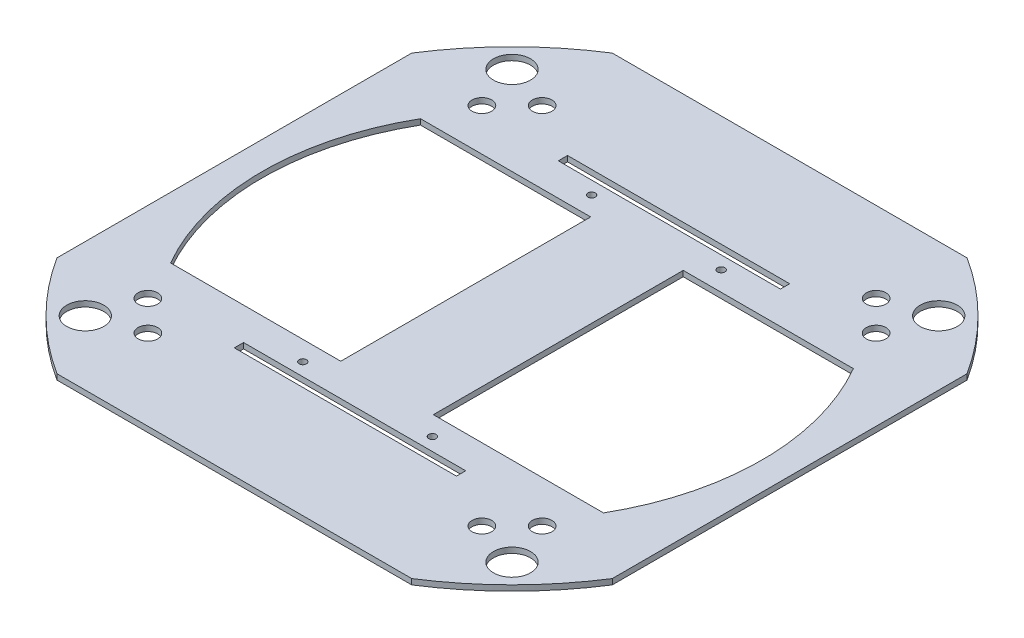
from build123d import *

# Parameters (mm, degrees)
SKETCH_3_R          = 178
EXTRUDE_3_DEPTH     = 3
SKETCH_4_R          = 10
SKETCH_4_R_2        = 5.3
CUT_EXTRUDE_1_DEPTH = 10
CUT_EXTRUDE_2_DEPTH = 10
SKETCH_6_R          = 2
SKETCH_6_W          = 120
SKETCH_6_H          = 5
CUT_EXTRUDE_3_DEPTH = 10


with BuildPart() as part:
    # 草图3 → 凸台-拉伸3 (new body)
    with BuildSketch(Plane(origin=(0, 0, 0), x_dir=(1, 0, 0), z_dir=(0, 1, 0))):
        Circle(SKETCH_3_R)
        with BuildLine():
            Line((-25, 33.75), (-25, -67.5))
            Line((-25, -67.5), (-116.913429511, -67.5))
            ThreePointArc((-116.913429511, -67.5), (-135, 0), (-116.913429511, 67.5))
            Line((-116.913429511, 67.5), (-25, 67.5))
            Line((-25, 67.5), (-25, 33.75))
        make_face(mode=Mode.SUBTRACT)
        with BuildLine():
            Line((25, 33.75), (25, 67.5))
            Line((25, 67.5), (116.913429511, 67.5))
            ThreePointArc((116.913429511, 67.5), (135, 0), (116.913429511, -67.5))
            Line((116.913429511, -67.5), (25, -67.5))
            Line((25, -67.5), (25, 33.75))
        make_face(mode=Mode.SUBTRACT)
    extrude(amount=EXTRUDE_3_DEPTH)

    # 草图4 → 切除-拉伸1 (cut)
    with BuildSketch(Plane(origin=(0, 3, 0), x_dir=(1, 0, 0), z_dir=(0, 1, 0))):
        with Locations((115.258405333, 115.258405333)):
            Circle(SKETCH_4_R)
        with Locations((115.258405333, -115.258405333)):
            Circle(SKETCH_4_R)
        with Locations((-115.258405333, -115.258405333)):
            Circle(SKETCH_4_R)
        with Locations((-115.258405333, 115.258405333)):
            Circle(SKETCH_4_R)
        with Locations((-90.216925784, -106.480381752)):
            Circle(SKETCH_4_R_2)
        with Locations((-106.480381752, -90.216925784)):
            Circle(SKETCH_4_R_2)
        with Locations((-106.480381752, 90.216925784)):
            Circle(SKETCH_4_R_2)
        with Locations((-90.216925784, 106.480381752)):
            Circle(SKETCH_4_R_2)
        with Locations((90.216925784, 106.480381752)):
            Circle(SKETCH_4_R_2)
        with Locations((106.480381752, 90.216925784)):
            Circle(SKETCH_4_R_2)
        with Locations((106.480381752, -90.216925784)):
            Circle(SKETCH_4_R_2)
        with Locations((90.216925784, -106.480381752)):
            Circle(SKETCH_4_R_2)
    extrude(amount=-CUT_EXTRUDE_1_DEPTH, mode=Mode.SUBTRACT)

    # 草图5 → 切除-拉伸2 (cut)
    with BuildSketch(Plane(origin=(0, 3, 0), x_dir=(1, 0, 0), z_dir=(0, 1, 0))):
        with BuildLine():
            Line((95.833188406, 150), (0, 150))
            Line((0, 150), (-95.833188406, 150))
            ThreePointArc((-95.833188406, 150), (0, 178), (95.833188406, 150))
        make_face()
        with BuildLine():
            Line((150, 95.833188406), (150, 0))
            Line((150, 0), (150, -95.833188406))
            ThreePointArc((150, -95.833188406), (178, 0), (150, 95.833188406))
        make_face()
        with BuildLine():
            Line((95.833188406, -150), (0, -150))
            Line((0, -150), (-95.833188406, -150))
            ThreePointArc((-95.833188406, -150), (0, -178), (95.833188406, -150))
        make_face()
        with BuildLine():
            Line((-150, 0), (-150, -95.833188406))
            ThreePointArc((-150, -95.833188406), (-178, 0), (-150, 95.833188406))
            Line((-150, 95.833188406), (-150, 0))
        make_face()
    extrude(amount=-CUT_EXTRUDE_2_DEPTH, mode=Mode.SUBTRACT)

    # 草图6 → 切除-拉伸3 (cut)
    with BuildSketch(Plane(origin=(0, 3, 0), x_dir=(1, 0, 0), z_dir=(0, 1, 0))):
        with Locations((35, -78)):
            Circle(SKETCH_6_R)
        with Locations((-35, -78)):
            Circle(SKETCH_6_R)
        with Locations((-35, 78)):
            Circle(SKETCH_6_R)
        with Locations((35, 78)):
            Circle(SKETCH_6_R)
        with Locations((0, -87.5)):
            Rectangle(SKETCH_6_W, SKETCH_6_H)
        with Locations((0, 87.5)):
            Rectangle(SKETCH_6_W, SKETCH_6_H)
    extrude(amount=-CUT_EXTRUDE_3_DEPTH, mode=Mode.SUBTRACT)


solid = part.part
